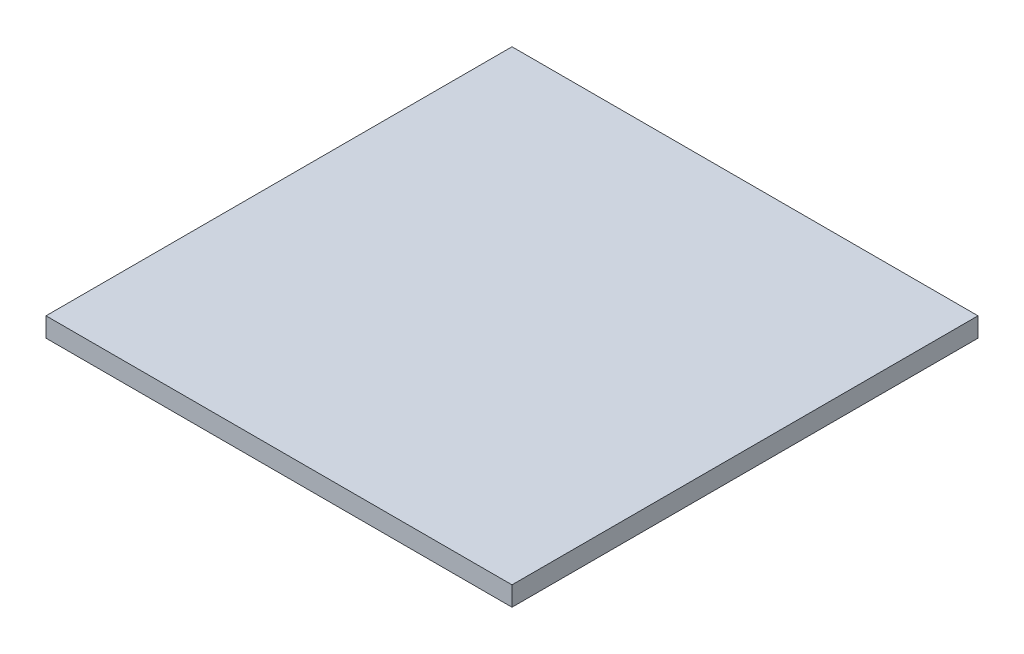
from build123d import *

# Parameters (mm, degrees)
SKETCH1_W           = 36
SKETCH1_H           = 36
BOSS_EXTRUDE1_DEPTH = 1.5


with BuildPart() as part:
    # Sketch1 → Boss-Extrude1 (new body)
    with BuildSketch(Plane(origin=(0, 0, 0), x_dir=(1, 0, 0), z_dir=(0, 1, 0))):
        Rectangle(SKETCH1_W, SKETCH1_H)
    extrude(amount=BOSS_EXTRUDE1_DEPTH)


solid = part.part
